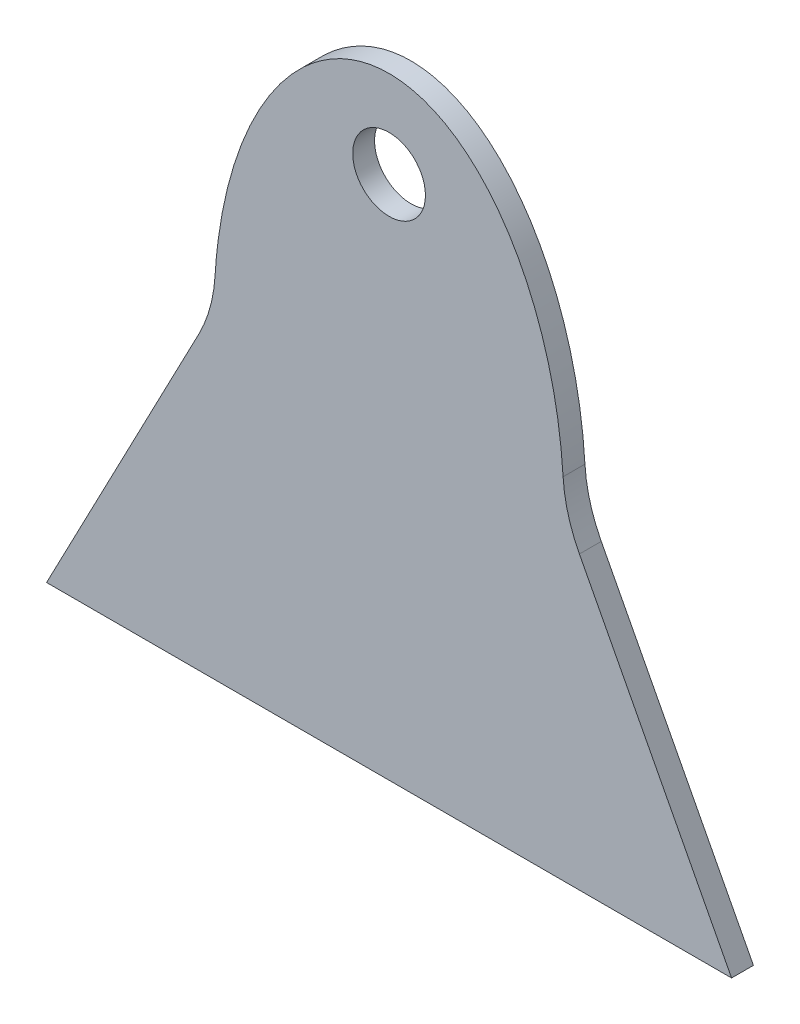
from build123d import *

# Parameters (mm, degrees)
SKETCH1_R           = 31.6865
BOSS_EXTRUDE1_DEPTH = 19.05
BOSS_EXTRUDE2_DEPTH = 19.05
FILLET1_R           = 127


with BuildPart() as part:
    # Sketch1 → Boss-Extrude1 (new body)
    with BuildSketch(Plane.XY):
        with BuildLine():
            Line((-152.4, 0), (152.4, 0))
            add(Edge.make_bspline(
                [(152.4, 0), (152.4, 254), (0, 254), (-152.4, 254), (-152.4, 0)],
                knots=[4.71238898, 4.71238898, 4.71238898, 6.283185307, 6.283185307, 7.853981634, 7.853981634, 7.853981634], degree=2, weights=[1, 0.707106781, 1, 0.707106781, 1]))
        make_face()
        with Locations((0, 177.8)):
            Circle(SKETCH1_R, mode=Mode.SUBTRACT)
    extrude(amount=BOSS_EXTRUDE1_DEPTH)

    # Sketch2 → Boss-Extrude2 (add)
    with BuildSketch(Plane.XY.offset(19.05)):
        Polygon((-152.4, 0), (-298.45, -279.4), (298.45, -279.4), (152.4, 0), align=None)
    extrude(amount=-BOSS_EXTRUDE2_DEPTH)

    # Fillet1
    fillet1_edges = [part.edges().sort_by_distance(p)[0] for p in [
        (-152.4, 0, 9.525),
        (152.4, 0, 9.525),
    ]]
    fillet(fillet1_edges, radius=FILLET1_R)


solid = part.part
